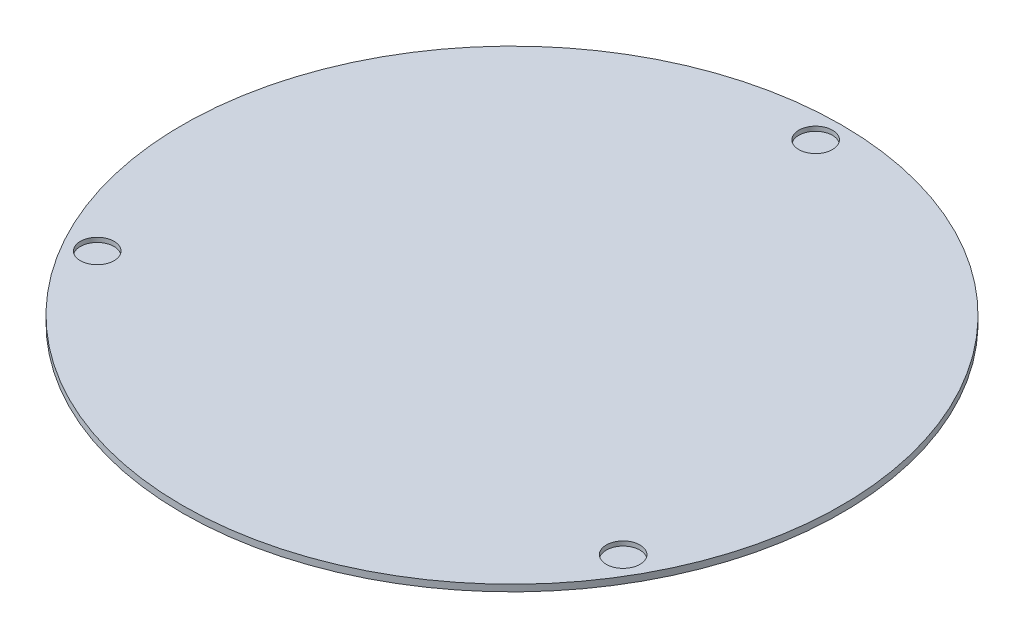
from build123d import *

# Parameters (mm, degrees)
SKETCH1_R           = 149.225
BOSS_EXTRUDE1_DEPTH = 3
SKETCH2_R           = 7.62
CUT_EXTRUDE1_DEPTH  = 2.032


with BuildPart() as part:
    # Sketch1 → Boss-Extrude1 (new body)
    with BuildSketch(Plane(origin=(0, 0, 0), x_dir=(1, 0, 0), z_dir=(0, 1, 0))):
        Circle(SKETCH1_R)
    extrude(amount=BOSS_EXTRUDE1_DEPTH)

    # Sketch2 → Cut-Extrude1 (cut)
    with BuildSketch(Plane(origin=(0, 3, 0), x_dir=(1, 0, 0), z_dir=(0, 1, 0))):
        with Locations((0, 137.4902)):
            Circle(SKETCH2_R)
        with Locations((119.070005971, -68.7451)):
            Circle(SKETCH2_R)
        with Locations((-119.070005971, -68.7451)):
            Circle(SKETCH2_R)
    extrude(amount=-CUT_EXTRUDE1_DEPTH, mode=Mode.SUBTRACT)


solid = part.part
